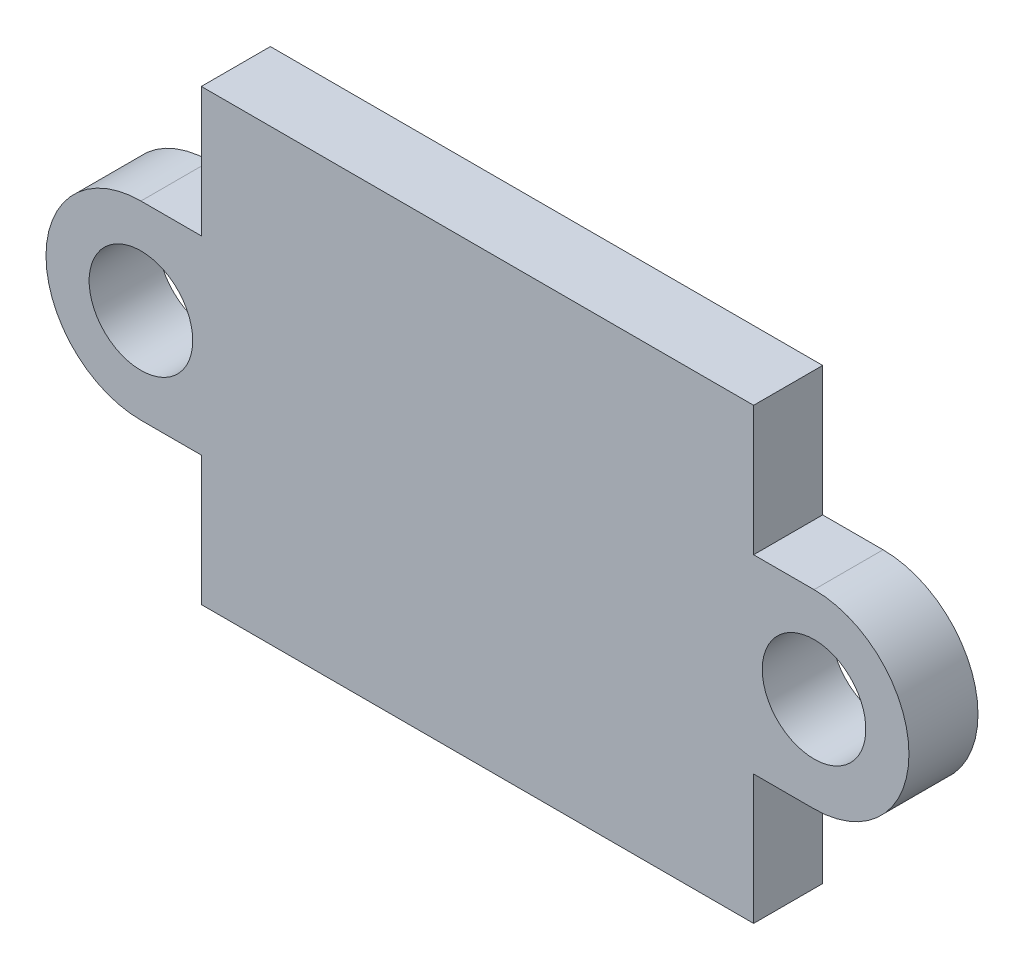
from build123d import *

# Parameters (mm, degrees)
SKETCH1_W           = 16
SKETCH1_H           = 13
BOSS_EXTRUDE1_DEPTH = 1
SKETCH2_R           = 1.5
BOSS_EXTRUDE2_DEPTH = 1


with BuildPart() as part:
    # Sketch1 → Boss-Extrude1 (new body, symmetric)
    with BuildSketch(Plane.XY):
        Rectangle(SKETCH1_W, SKETCH1_H)
    extrude(amount=BOSS_EXTRUDE1_DEPTH, both=True)

    # Sketch2 → Boss-Extrude2 (add, symmetric)
    with BuildSketch(Plane.XY):
        with BuildLine():
            Line((-9.75, 2.75), (-8, 2.75))
            Line((-8, 2.75), (-8, -2.75))
            Line((-8, -2.75), (-9.75, -2.75))
            ThreePointArc((-9.75, -2.75), (-12.5, 0), (-9.75, 2.75))
        make_face()
        with Locations((-9.75, 0)):
            Circle(SKETCH2_R, mode=Mode.SUBTRACT)
        with BuildLine():
            Line((9.75, -2.75), (8, -2.75))
            Line((8, -2.75), (8, 2.75))
            Line((8, 2.75), (9.75, 2.75))
            ThreePointArc((9.75, 2.75), (12.5, 0), (9.75, -2.75))
        make_face()
        with Locations((9.75, 0)):
            Circle(SKETCH2_R, mode=Mode.SUBTRACT)
    extrude(amount=BOSS_EXTRUDE2_DEPTH, both=True)


solid = part.part
